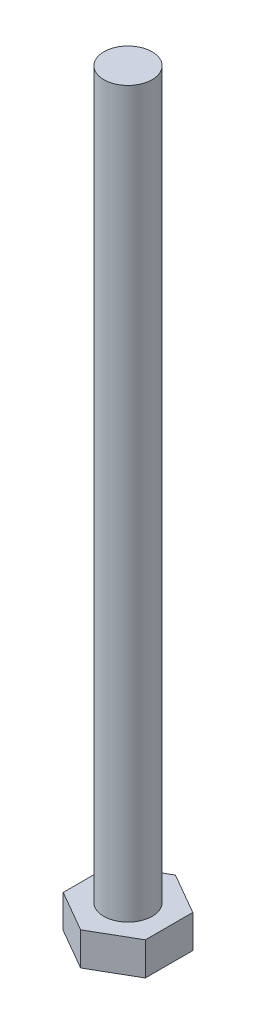
from build123d import *

# Parameters (mm, degrees)
EXTRUDE_1_DEPTH = 8
SKETCH_2_R      = 5
EXTRUDE_2_DEPTH = 150
CHAMFER_1_SIZE  = 2
CHAMFER_1_SIZE2 = 1.154700538


with BuildPart() as part:
    # Эскиз1 → Бобышка-Вытянуть1 (new body)
    with BuildSketch(Plane(origin=(0, 0, 0), x_dir=(1, 0, 0), z_dir=(0, 1, 0))):
        Polygon((8.5, -4.907477288), (8.5, 4.907477288), (0, 9.814954576), (-8.5, 4.907477288), (-8.5, -4.907477288), (0, -9.814954576), align=None)
    extrude(amount=EXTRUDE_1_DEPTH)

    # Эскиз2 → Бобышка-Вытянуть2 (add)
    with BuildSketch(Plane(origin=(0, 8, 0), x_dir=(1, 0, 0), z_dir=(0, 1, 0))):
        Circle(SKETCH_2_R)
    extrude(amount=EXTRUDE_2_DEPTH)

    # Фаска1
    chamfer_1_edges = [part.edges().sort_by_distance(p)[0] for p in [
        (-4.25, 0, 7.361215932),
        (-8.5, 0, 0),
        (-4.25, 0, -7.361215932),
        (4.25, 0, -7.361215932),
        (8.5, 0, 0),
        (4.25, 0, 7.361215932),
    ]]
    chamfer_1_side = [part.faces().sort_by_distance(p)[0] for p in [
        (0, 0, 0),
    ]]
    chamfer(chamfer_1_edges, length=CHAMFER_1_SIZE, length2=CHAMFER_1_SIZE2, reference=chamfer_1_side[0])


solid = part.part
